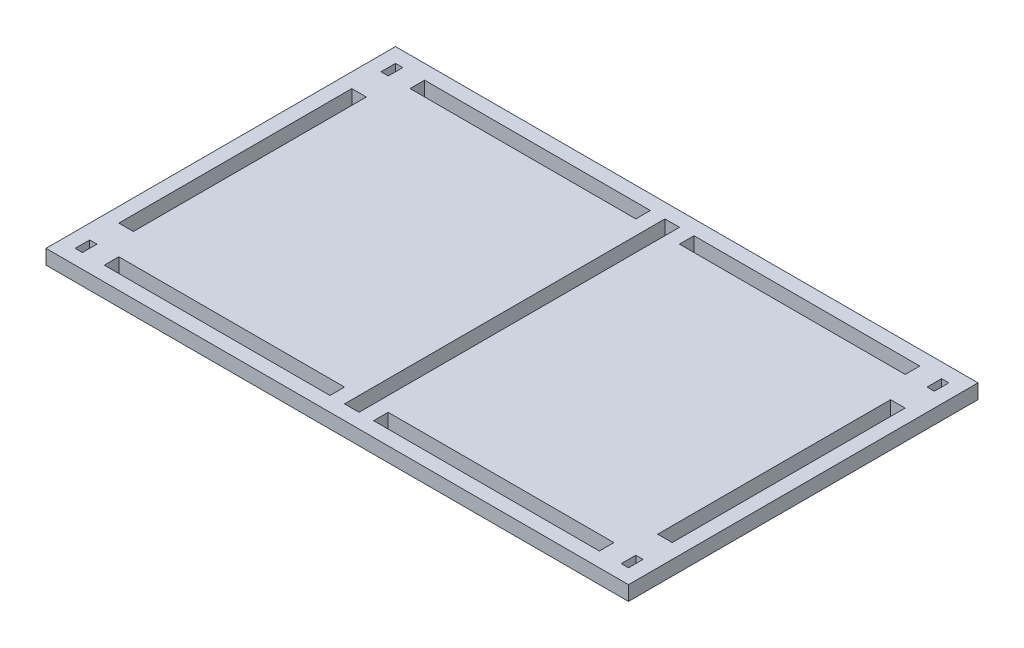
from build123d import *

# Parameters (mm, degrees)
SKETCH1_W           = 254
SKETCH1_H           = 152.4
SKETCH1_W_2         = 6.35
SKETCH1_H_2         = 101.6
SKETCH1_H_3         = 139.7
SKETCH1_W_3         = 98.425
SKETCH1_H_4         = 6.34492
SKETCH1_W_4         = 3.175
BOSS_EXTRUDE1_DEPTH = 6.35


with BuildPart() as part:
    # Sketch1 → Boss-Extrude1 (new body)
    with BuildSketch(Plane(origin=(0, 0, 0), x_dir=(1, 0, 0), z_dir=(0, 1, 0))):
        Rectangle(SKETCH1_W, SKETCH1_H)
        with Locations((117.475, 0)):
            Rectangle(SKETCH1_W_2, SKETCH1_H_2, mode=Mode.SUBTRACT)
        Rectangle(SKETCH1_W_2, SKETCH1_H_3, mode=Mode.SUBTRACT)
        with Locations((-117.475, 0)):
            Rectangle(SKETCH1_W_2, SKETCH1_H_2, mode=Mode.SUBTRACT)
        with Locations((-58.7375, 66.67754)):
            Rectangle(SKETCH1_W_3, SKETCH1_H_4, mode=Mode.SUBTRACT)
        with Locations((58.7375, -66.68262)):
            Rectangle(SKETCH1_W_3, SKETCH1_H_4, mode=Mode.SUBTRACT)
        with Locations((58.7375, 66.67754)):
            Rectangle(SKETCH1_W_3, SKETCH1_H_4, mode=Mode.SUBTRACT)
        with Locations((-58.7375, -66.67754)):
            Rectangle(SKETCH1_W_3, SKETCH1_H_4, mode=Mode.SUBTRACT)
        with Locations((-119.0625, -66.67754)):
            Rectangle(SKETCH1_W_4, SKETCH1_H_4, mode=Mode.SUBTRACT)
        with Locations((119.0625, -66.67754)):
            Rectangle(SKETCH1_W_4, SKETCH1_H_4, mode=Mode.SUBTRACT)
        with Locations((-119.0625, 66.67754)):
            Rectangle(SKETCH1_W_4, SKETCH1_H_4, mode=Mode.SUBTRACT)
        with Locations((119.0625, 66.67754)):
            Rectangle(SKETCH1_W_4, SKETCH1_H_4, mode=Mode.SUBTRACT)
    extrude(amount=BOSS_EXTRUDE1_DEPTH)


solid = part.part
